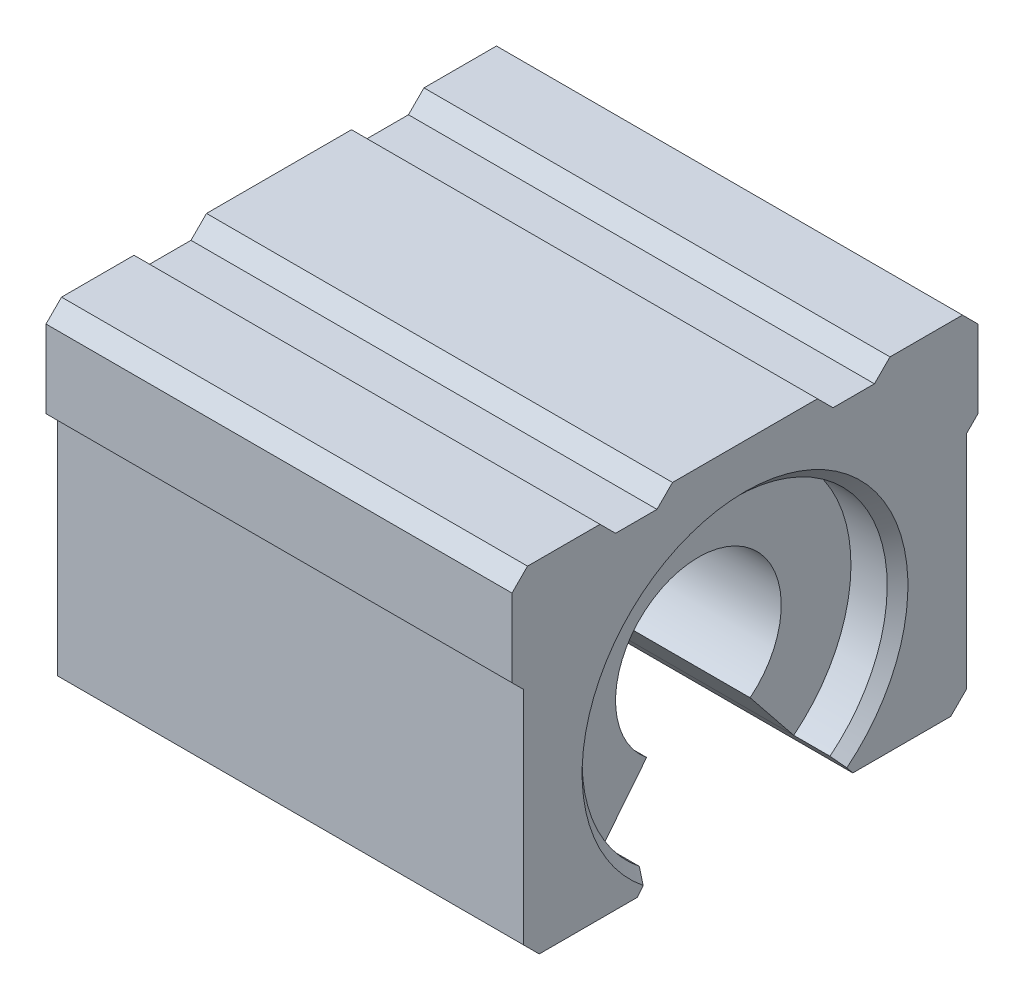
from build123d import *

# Parameters (mm, degrees)
BOSS_EXTRUDE1_DEPTH = 45
CUT_EXTRUDE1_DEPTH  = 4.5
CUT_EXTRUDE2_DEPTH  = 4.5
CHAMFER3_SIZE       = 1
CHAMFER4_SIZE       = 1
CUT_EXTRUDE3_DEPTH  = 36


with BuildPart() as part:
    # Sketch1 → Boss-Extrude1 (new body)
    with BuildSketch(Plane(origin=(0, 0, 0), x_dir=(0, 0, -1), z_dir=(1, 0, 0))):
        Polygon((-22.5, 18.5), (-21, 20), (-14, 20), (-12.5, 18.5), (-8.5, 18.5), (-7, 20), (7, 20), (8.5, 18.5), (12.5, 18.5), (14, 20), (21, 20), (22.5, 18.5), (22.5, 11), (21.36862915, 9.86862915), (21.36862915, -11.5), (19.86862915, -13), (10.408329997, -13), (9.207368844, -11.5), (-9.207368844, -11.5), (-10.408329997, -13), (-19.86862915, -13), (-21.36862915, -11.5), (-21.36862915, 9.86862915), (-22.5, 11), align=None)
    extrude(amount=BOSS_EXTRUDE1_DEPTH)

    # Sketch8 → Cut-Extrude1 (cut)
    with BuildSketch(Plane.ZY):
        with BuildLine():
            Line((-9.207368844, -11.5), (9.207368844, -11.5))
            ThreePointArc((9.207368844, -11.5), (0, 14.73179015), (-9.207368844, -11.5))
        make_face()
    extrude(amount=-CUT_EXTRUDE1_DEPTH, mode=Mode.SUBTRACT)

    # Sketch9 → Cut-Extrude2 (cut)
    with BuildSketch(Plane(origin=(45, 0, 0), x_dir=(0, 0, -1), z_dir=(1, 0, 0))):
        with BuildLine():
            Line((-9.207368844, -11.5), (9.207368844, -11.5))
            ThreePointArc((9.207368844, -11.5), (0, 14.73179015), (-9.207368844, -11.5))
        make_face()
    extrude(amount=-CUT_EXTRUDE2_DEPTH, mode=Mode.SUBTRACT)

    # Chamfer3
    chamfer3_edges = [part.edges().sort_by_distance(p)[0] for p in [
        (45, 14.73179015, 0),
    ]]
    chamfer(chamfer3_edges, length=CHAMFER3_SIZE)

    # Chamfer4
    chamfer4_edges = [part.edges().sort_by_distance(p)[0] for p in [
        (0, 14.73179015, 0),
    ]]
    chamfer(chamfer4_edges, length=CHAMFER4_SIZE)

    # Sketch10 → Cut-Extrude3 (cut)
    with BuildSketch(Plane(origin=(40.5, 0, 0), x_dir=(0, 0, -1), z_dir=(1, 0, 0))):
        with BuildLine():
            ThreePointArc((-5, -6.244997998), (0.003880032, 7.999999059), (4.99393995, -6.2498451))
            Line((4.99393995, -6.2498451), (9.207368844, -11.5))
            Line((9.207368844, -11.5), (-9.207368844, -11.5))
            Line((-9.207368844, -11.5), (-5, -6.244997998))
        make_face()
    extrude(amount=-CUT_EXTRUDE3_DEPTH, mode=Mode.SUBTRACT)


solid = part.part
